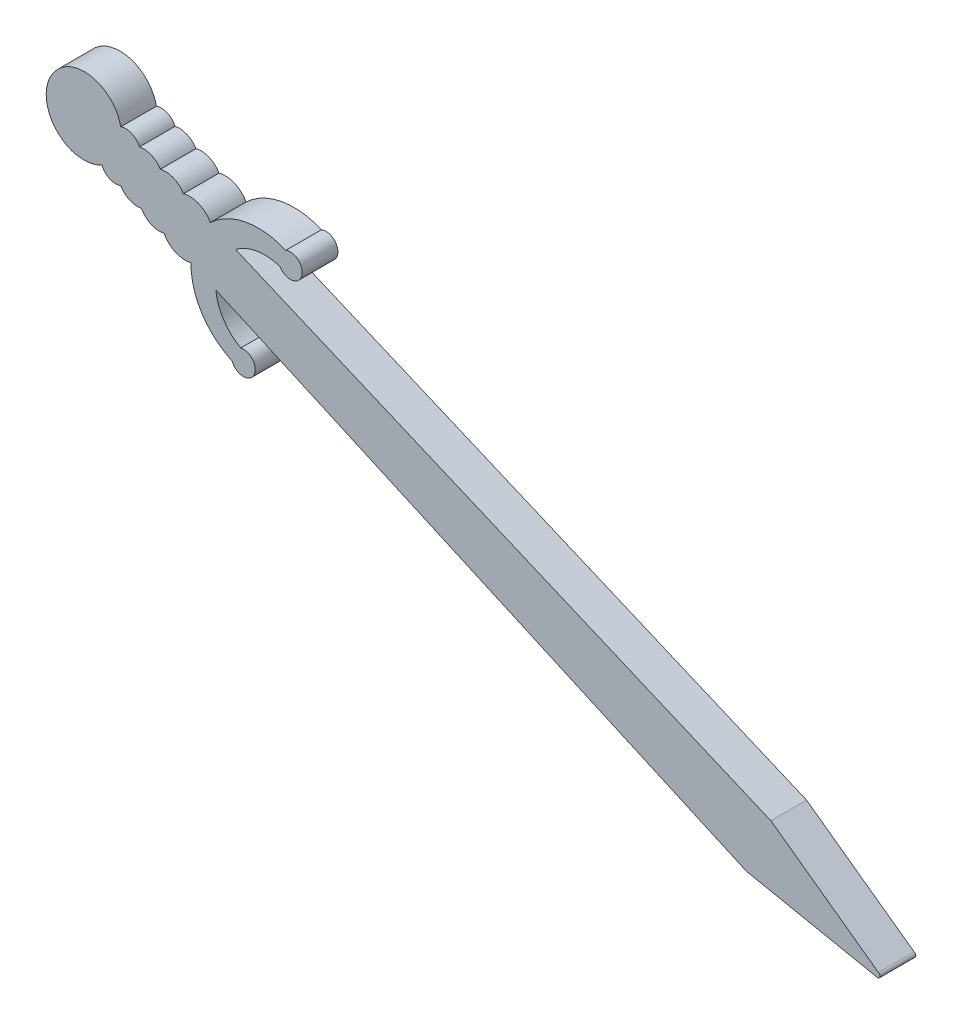
from build123d import *

# Parameters (mm, degrees)
SALIENTE_EXTRUIR1_DEPTH = 3


with BuildPart() as part:
    # Model → Saliente-Extruir1 (new body)
    with BuildSketch(Plane.XY):
        with BuildLine():
            Line((66.714016933, 2.675368226), (68.538077011, 2.306726339))
            ThreePointArc((68.538077011, 2.306726339), (68.813397969, 2.426362589), (68.69376172, 2.701683548))
            Line((68.69376172, 2.701683548), (59.642778757, 9.23296694))
            Line((59.642778757, 9.23296694), (18.229236322, 26.798350869))
            Line((18.229236322, 26.798350869), (14.628932536, 28.325404932))
            ThreePointArc((14.628932536, 28.325404932), (16.425259576, 29.101436048), (18.375877707, 28.946181294))
            ThreePointArc((18.375877707, 28.946181294), (20.18694444, 29.13171328), (18.856885424, 30.37482544))
            ThreePointArc((18.856885424, 30.37482544), (15.51300149, 30.748167733), (12.514190479, 29.22236409))
            ThreePointArc((12.514190479, 29.22236409), (11.546461676, 30.101035899), (10.242109559, 30.186057881))
            ThreePointArc((10.242109559, 30.186057881), (9.413998041, 30.920271825), (8.310546545, 31.005322399))
            ThreePointArc((8.310546545, 31.005322399), (7.548095898, 31.654909282), (6.551125432, 31.751573638))
            ThreePointArc((6.551125432, 31.751573638), (5.898852104, 32.399314767), (4.980282277, 32.434790623))
            ThreePointArc((4.980282277, 32.434790623), (2.50269425, 34.859987429), (-0.691279819, 33.511450585))
            ThreePointArc((-0.691279819, 33.511450585), (-1.245238827, 31.123095112), (0.062521474, 29.0492399))
            ThreePointArc((0.062521474, 29.0492399), (0.732684306, 28.668767636), (1.483760549, 28.496251432))
            ThreePointArc((1.483760549, 28.496251432), (2.467023265, 28.521711274), (3.395589179, 28.846086231))
            ThreePointArc((3.395589179, 28.846086231), (4.04475241, 28.180155342), (4.973767828, 28.137644119))
            ThreePointArc((4.973767828, 28.137644119), (5.722549371, 27.472346961), (6.71729481, 27.354977378))
            ThreePointArc((6.71729481, 27.354977378), (7.529963713, 26.603706418), (8.63140861, 26.495734463))
            ThreePointArc((8.63140861, 26.495734463), (9.580661475, 25.59713434), (10.88296417, 25.485014428))
            ThreePointArc((10.88296417, 25.485014428), (11.803253278, 22.248656569), (14.350721609, 20.050623508))
            ThreePointArc((14.350721609, 20.050623508), (16.16662002, 19.920632003), (15.071202926, 21.374745554))
            ThreePointArc((15.071202926, 21.374745554), (13.631015332, 22.699462439), (12.978602224, 24.544285537))
            Line((12.978602224, 24.544285537), (16.546381847, 22.942714426))
            Line((16.546381847, 22.942714426), (57.585805628, 4.520176455))
            Line((57.585805628, 4.520176455), (66.714016933, 2.675368226))
        make_face()
    extrude(amount=SALIENTE_EXTRUIR1_DEPTH)


solid = part.part
